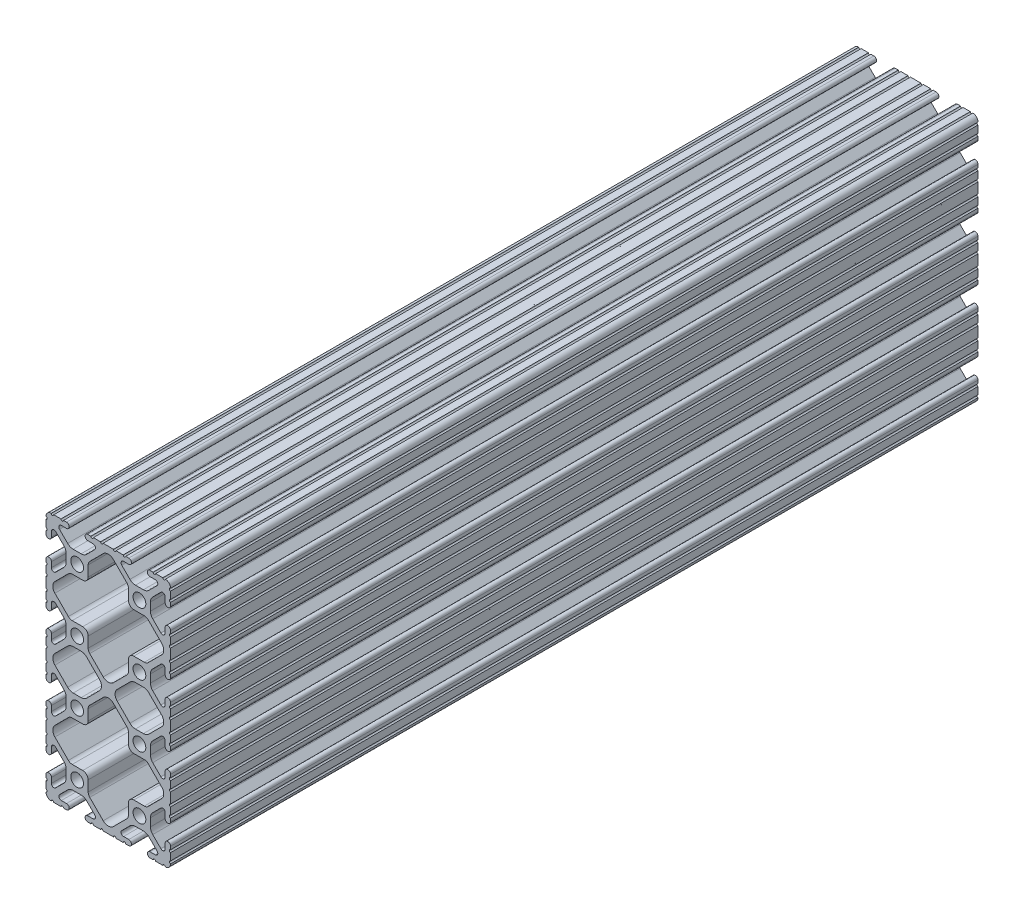
from build123d import *

# Parameters (mm, degrees)
SKETCH1_R      = 2.6035
EXTRUDE1_DEPTH = 329.311


with BuildPart() as part:
    # Sketch1 → Extrude1 (new body)
    with BuildSketch(Plane.XY):
        with BuildLine():
            Line((-12.699984366, 40.2336), (-12.699984366, 35.9664))
            ThreePointArc((-12.699984366, 35.9664), (-12.192, 35.458392183), (-12.7, 34.9504))
            Line((-12.7, 34.9504), (-12.7, 32.004))
            ThreePointArc((-12.7, 32.004), (-12.192, 31.496), (-12.7, 30.988))
            Line((-12.7, 30.988), (-12.7, 29.7434))
            ThreePointArc((-12.7, 29.7434), (-11.5951, 28.6385), (-10.4902, 29.7434))
            Line((-10.4902, 29.7434), (-10.4902, 31.874256981))
            ThreePointArc((-10.4902, 31.874256981), (-9.863010627, 32.812916821), (-8.755786031, 32.592683991))
            Line((-8.755786031, 32.592683991), (-5.425756348, 29.262714761))
            ThreePointArc((-5.425756348, 29.262714761), (-4.737487999, 28.232663563), (-4.4958, 27.017630353))
            Line((-4.4958, 27.017630353), (-4.4958, 23.782369647))
            ThreePointArc((-4.4958, 23.782369647), (-4.737487999, 22.567336437), (-5.425756348, 21.537285239))
            Line((-5.425756348, 21.537285239), (-8.755786031, 18.207316009))
            ThreePointArc((-8.755786031, 18.207316009), (-9.863010627, 17.987083179), (-10.4902, 18.925743019))
            Line((-10.4902, 18.925743019), (-10.4902, 21.0566))
            ThreePointArc((-10.4902, 21.0566), (-11.5951, 22.1615), (-12.7, 21.0566))
            Line((-12.7, 21.0566), (-12.7, 19.812))
            ThreePointArc((-12.7, 19.812), (-12.192, 19.304), (-12.7, 18.796))
            Line((-12.7, 18.796), (-12.7, 15.8496))
            ThreePointArc((-12.7, 15.8496), (-12.192, 15.341607817), (-12.699984366, 14.8336))
            Line((-12.699984366, 14.8336), (-12.699984366, 10.5664))
            ThreePointArc((-12.699984366, 10.5664), (-12.192, 10.0584), (-12.699984366, 9.5504))
            Line((-12.699984366, 9.5504), (-12.699984366, 6.604))
            ThreePointArc((-12.699984366, 6.604), (-12.192, 6.095992183), (-12.7, 5.588))
            Line((-12.7, 5.588), (-12.7, 4.3434))
            ThreePointArc((-12.7, 4.3434), (-11.5951, 3.2385), (-10.4902, 4.3434))
            Line((-10.4902, 4.3434), (-10.4902, 6.474256981))
            ThreePointArc((-10.4902, 6.474256981), (-9.863010627, 7.412916821), (-8.755786031, 7.192683991))
            Line((-8.755786031, 7.192683991), (-5.425756348, 3.862714761))
            ThreePointArc((-5.425756348, 3.862714761), (-4.737487999, 2.832663563), (-4.4958, 1.617630353))
            Line((-4.4958, 1.617630353), (-4.4958, -1.617630353))
            ThreePointArc((-4.4958, -1.617630353), (-4.737487999, -2.832663563), (-5.425756348, -3.862714761))
            Line((-5.425756348, -3.862714761), (-8.755786031, -7.192683991))
            ThreePointArc((-8.755786031, -7.192683991), (-9.863010627, -7.412916821), (-10.4902, -6.474256981))
            Line((-10.4902, -6.474256981), (-10.4902, -4.3434))
            ThreePointArc((-10.4902, -4.3434), (-11.5951, -3.2385), (-12.7, -4.3434))
            Line((-12.7, -4.3434), (-12.7, -5.588))
            ThreePointArc((-12.7, -5.588), (-12.192, -6.096), (-12.7, -6.604))
            Line((-12.7, -6.604), (-12.7, -9.5504))
            ThreePointArc((-12.7, -9.5504), (-12.192000007, -10.058315768), (-12.699831537, -10.566399972))
            ThreePointArc((-12.699831537, -10.566399972), (-12.082506882, -12.082506882), (-10.566399972, -12.699831537))
            ThreePointArc((-10.566399972, -12.699831537), (-10.058315768, -12.192000007), (-9.5504, -12.7))
            Line((-9.5504, -12.7), (-6.604, -12.7))
            ThreePointArc((-6.604, -12.7), (-6.096, -12.192), (-5.588, -12.7))
            Line((-5.588, -12.7), (-4.3434, -12.7))
            ThreePointArc((-4.3434, -12.7), (-3.2385, -11.5951), (-4.3434, -10.4902))
            Line((-4.3434, -10.4902), (-6.474256981, -10.4902))
            ThreePointArc((-6.474256981, -10.4902), (-7.412916821, -9.863010627), (-7.192683991, -8.755786031))
            Line((-7.192683991, -8.755786031), (-3.862714761, -5.425756348))
            ThreePointArc((-3.862714761, -5.425756348), (-2.832663563, -4.737487999), (-1.617630353, -4.4958))
            Line((-1.617630353, -4.4958), (1.617630353, -4.4958))
            ThreePointArc((1.617630353, -4.4958), (2.832663563, -4.737487999), (3.862714761, -5.425756348))
            Line((3.862714761, -5.425756348), (7.192683991, -8.755786031))
            ThreePointArc((7.192683991, -8.755786031), (7.412916821, -9.863010627), (6.474256981, -10.4902))
            Line((6.474256981, -10.4902), (4.3434, -10.4902))
            ThreePointArc((4.3434, -10.4902), (3.2385, -11.5951), (4.3434, -12.7))
            Line((4.3434, -12.7), (5.588, -12.7))
            ThreePointArc((5.588, -12.7), (6.096, -12.192), (6.604, -12.7))
            Line((6.604, -12.7), (9.5504, -12.7))
            ThreePointArc((9.5504, -12.7), (10.0584, -12.192), (10.5664, -12.7))
            Line((10.5664, -12.7), (14.8336, -12.7))
            ThreePointArc((14.8336, -12.7), (15.3416, -12.192), (15.8496, -12.7))
            Line((15.8496, -12.7), (18.796, -12.7))
            ThreePointArc((18.796, -12.7), (19.304, -12.192), (19.812, -12.7))
            Line((19.812, -12.7), (21.0566, -12.7))
            ThreePointArc((21.0566, -12.7), (22.1615, -11.5951), (21.0566, -10.4902))
            Line((21.0566, -10.4902), (18.925743019, -10.4902))
            ThreePointArc((18.925743019, -10.4902), (17.987083179, -9.863010627), (18.207316009, -8.755786031))
            Line((18.207316009, -8.755786031), (21.537285239, -5.425756348))
            ThreePointArc((21.537285239, -5.425756348), (22.567336437, -4.737487999), (23.782369647, -4.4958))
            Line((23.782369647, -4.4958), (27.017630353, -4.4958))
            ThreePointArc((27.017630353, -4.4958), (28.232663563, -4.737487999), (29.262714761, -5.425756348))
            Line((29.262714761, -5.425756348), (32.592683991, -8.755786031))
            ThreePointArc((32.592683991, -8.755786031), (32.812916821, -9.863010627), (31.874256981, -10.4902))
            Line((31.874256981, -10.4902), (29.7434, -10.4902))
            ThreePointArc((29.7434, -10.4902), (28.6385, -11.5951), (29.7434, -12.7))
            Line((29.7434, -12.7), (30.988, -12.7))
            ThreePointArc((30.988, -12.7), (31.496, -12.192), (32.004, -12.7))
            Line((32.004, -12.7), (34.9504, -12.7))
            ThreePointArc((34.9504, -12.7), (35.458315768, -12.192000007), (35.966399972, -12.699831537))
            ThreePointArc((35.966399972, -12.699831537), (37.482506882, -12.082506882), (38.099831537, -10.566399972))
            ThreePointArc((38.099831537, -10.566399972), (37.592000007, -10.058315768), (38.1, -9.5504))
            Line((38.1, -9.5504), (38.1, -6.604))
            ThreePointArc((38.1, -6.604), (37.592, -6.096), (38.1, -5.588))
            Line((38.1, -5.588), (38.1, -4.3434))
            ThreePointArc((38.1, -4.3434), (36.9951, -3.2385), (35.8902, -4.3434))
            Line((35.8902, -4.3434), (35.8902, -6.474256981))
            ThreePointArc((35.8902, -6.474256981), (35.263010627, -7.412916821), (34.155786031, -7.192683991))
            Line((34.155786031, -7.192683991), (30.825756348, -3.862714761))
            ThreePointArc((30.825756348, -3.862714761), (30.137487999, -2.832663563), (29.8958, -1.617630353))
            Line((29.8958, -1.617630353), (29.8958, 1.617630353))
            ThreePointArc((29.8958, 1.617630353), (30.137487999, 2.832663563), (30.825756348, 3.862714761))
            Line((30.825756348, 3.862714761), (34.155786031, 7.192683991))
            ThreePointArc((34.155786031, 7.192683991), (35.263010627, 7.412916821), (35.8902, 6.474256981))
            Line((35.8902, 6.474256981), (35.8902, 4.3434))
            ThreePointArc((35.8902, 4.3434), (36.9951, 3.2385), (38.1, 4.3434))
            Line((38.1, 4.3434), (38.1, 5.588))
            ThreePointArc((38.1, 5.588), (37.592, 6.096), (38.1, 6.604))
            Line((38.1, 6.604), (38.1, 9.5504))
            ThreePointArc((38.1, 9.5504), (37.592, 10.058392183), (38.099984366, 10.5664))
            Line((38.099984366, 10.5664), (38.099984366, 14.8336))
            ThreePointArc((38.099984366, 14.8336), (37.592, 15.3416), (38.099984366, 15.8496))
            Line((38.099984366, 15.8496), (38.099984366, 18.796))
            ThreePointArc((38.099984366, 18.796), (37.592, 19.304007817), (38.1, 19.812))
            Line((38.1, 19.812), (38.1, 21.0566))
            ThreePointArc((38.1, 21.0566), (36.9951, 22.1615), (35.8902, 21.0566))
            Line((35.8902, 21.0566), (35.8902, 18.925743019))
            ThreePointArc((35.8902, 18.925743019), (35.263010627, 17.987083179), (34.155786031, 18.207316009))
            Line((34.155786031, 18.207316009), (30.825756348, 21.537285239))
            ThreePointArc((30.825756348, 21.537285239), (30.137487999, 22.567336437), (29.8958, 23.782369647))
            Line((29.8958, 23.782369647), (29.8958, 27.017630353))
            ThreePointArc((29.8958, 27.017630353), (30.137487999, 28.232663563), (30.825756348, 29.262714761))
            Line((30.825756348, 29.262714761), (34.155786031, 32.592683991))
            ThreePointArc((34.155786031, 32.592683991), (35.263010627, 32.812916821), (35.8902, 31.874256981))
            Line((35.8902, 31.874256981), (35.8902, 29.7434))
            ThreePointArc((35.8902, 29.7434), (36.9951, 28.6385), (38.1, 29.7434))
            Line((38.1, 29.7434), (38.1, 30.988))
            ThreePointArc((38.1, 30.988), (37.592, 31.495992183), (38.099984366, 32.004))
            Line((38.099984366, 32.004), (38.099984366, 34.9504))
            ThreePointArc((38.099984366, 34.9504), (37.592, 35.4584), (38.099984366, 35.9664))
            Line((38.099984366, 35.9664), (38.099984366, 40.2336))
            ThreePointArc((38.099984366, 40.2336), (37.592, 40.7416), (38.099984366, 41.2496))
            Line((38.099984366, 41.2496), (38.099984366, 44.196))
            ThreePointArc((38.099984366, 44.196), (37.592, 44.704007817), (38.1, 45.212))
            Line((38.1, 45.212), (38.1, 46.4566))
            ThreePointArc((38.1, 46.4566), (36.9951, 47.5615), (35.8902, 46.4566))
            Line((35.8902, 46.4566), (35.8902, 44.325743019))
            ThreePointArc((35.8902, 44.325743019), (35.263010627, 43.387083179), (34.155786031, 43.607316009))
            Line((34.155786031, 43.607316009), (30.825756348, 46.937285239))
            ThreePointArc((30.825756348, 46.937285239), (30.137487999, 47.967336437), (29.8958, 49.182369647))
            Line((29.8958, 49.182369647), (29.8958, 52.417630353))
            ThreePointArc((29.8958, 52.417630353), (30.137487999, 53.632663563), (30.825756348, 54.662714761))
            Line((30.825756348, 54.662714761), (34.155786031, 57.992683991))
            ThreePointArc((34.155786031, 57.992683991), (35.263010627, 58.212916821), (35.8902, 57.274256981))
            Line((35.8902, 57.274256981), (35.8902, 55.1434))
            ThreePointArc((35.8902, 55.1434), (36.9951, 54.0385), (38.1, 55.1434))
            Line((38.1, 55.1434), (38.1, 56.388))
            ThreePointArc((38.1, 56.388), (37.592, 56.896), (38.1, 57.404))
            Line((38.1, 57.404), (38.1, 60.3504))
            ThreePointArc((38.1, 60.3504), (37.592, 60.858392183), (38.099984366, 61.3664))
            Line((38.099984366, 61.3664), (38.099984366, 65.6336))
            ThreePointArc((38.099984366, 65.6336), (37.592, 66.141607817), (38.1, 66.6496))
            Line((38.1, 66.6496), (38.1, 69.596))
            ThreePointArc((38.1, 69.596), (37.592, 70.104), (38.1, 70.612))
            Line((38.1, 70.612), (38.1, 71.8566))
            ThreePointArc((38.1, 71.8566), (36.9951, 72.9615), (35.8902, 71.8566))
            Line((35.8902, 71.8566), (35.8902, 69.725743019))
            ThreePointArc((35.8902, 69.725743019), (35.263010627, 68.787083179), (34.155786031, 69.007316009))
            Line((34.155786031, 69.007316009), (30.825756348, 72.337285239))
            ThreePointArc((30.825756348, 72.337285239), (30.137487999, 73.367336437), (29.8958, 74.582369647))
            Line((29.8958, 74.582369647), (29.8958, 77.817630353))
            ThreePointArc((29.8958, 77.817630353), (30.137487999, 79.032663563), (30.825756348, 80.062714761))
            Line((30.825756348, 80.062714761), (34.155786031, 83.392683991))
            ThreePointArc((34.155786031, 83.392683991), (35.263010627, 83.612916821), (35.8902, 82.674256981))
            Line((35.8902, 82.674256981), (35.8902, 80.5434))
            ThreePointArc((35.8902, 80.5434), (36.9951, 79.4385), (38.1, 80.5434))
            Line((38.1, 80.5434), (38.1, 81.788))
            ThreePointArc((38.1, 81.788), (37.592, 82.296), (38.1, 82.804))
            Line((38.1, 82.804), (38.1, 85.7504))
            ThreePointArc((38.1, 85.7504), (37.592000007, 86.258315768), (38.099831537, 86.766399972))
            ThreePointArc((38.099831537, 86.766399972), (37.482506882, 88.282506882), (35.966399972, 88.899831537))
            ThreePointArc((35.966399972, 88.899831537), (35.458315768, 88.392000007), (34.9504, 88.9))
            Line((34.9504, 88.9), (32.004, 88.9))
            ThreePointArc((32.004, 88.9), (31.496, 88.392), (30.988, 88.9))
            Line((30.988, 88.9), (29.7434, 88.9))
            ThreePointArc((29.7434, 88.9), (28.6385, 87.7951), (29.7434, 86.6902))
            Line((29.7434, 86.6902), (31.874256981, 86.6902))
            ThreePointArc((31.874256981, 86.6902), (32.812916821, 86.063010627), (32.592683991, 84.955786031))
            Line((32.592683991, 84.955786031), (29.262714761, 81.625756348))
            ThreePointArc((29.262714761, 81.625756348), (28.232663563, 80.937487999), (27.017630353, 80.6958))
            Line((27.017630353, 80.6958), (23.782369647, 80.6958))
            ThreePointArc((23.782369647, 80.6958), (22.567336437, 80.937487999), (21.537285239, 81.625756348))
            Line((21.537285239, 81.625756348), (18.207316009, 84.955786031))
            ThreePointArc((18.207316009, 84.955786031), (17.987083179, 86.063010627), (18.925743019, 86.6902))
            Line((18.925743019, 86.6902), (21.0566, 86.6902))
            ThreePointArc((21.0566, 86.6902), (22.1615, 87.7951), (21.0566, 88.9))
            Line((21.0566, 88.9), (19.812, 88.9))
            ThreePointArc((19.812, 88.9), (19.304, 88.392), (18.796, 88.9))
            Line((18.796, 88.9), (15.8496, 88.9))
            ThreePointArc((15.8496, 88.9), (15.3416, 88.392), (14.8336, 88.9))
            Line((14.8336, 88.9), (10.5664, 88.9))
            ThreePointArc((10.5664, 88.9), (10.0584, 88.392), (9.5504, 88.9))
            Line((9.5504, 88.9), (6.604, 88.9))
            ThreePointArc((6.604, 88.9), (6.096, 88.392), (5.588, 88.9))
            Line((5.588, 88.9), (4.3434, 88.9))
            ThreePointArc((4.3434, 88.9), (3.2385, 87.7951), (4.3434, 86.6902))
            Line((4.3434, 86.6902), (6.474256981, 86.6902))
            ThreePointArc((6.474256981, 86.6902), (7.412916821, 86.063010627), (7.192683991, 84.955786031))
            Line((7.192683991, 84.955786031), (3.862714761, 81.625756348))
            ThreePointArc((3.862714761, 81.625756348), (2.832663563, 80.937487999), (1.617630353, 80.6958))
            Line((1.617630353, 80.6958), (-1.617630353, 80.6958))
            ThreePointArc((-1.617630353, 80.6958), (-2.832663563, 80.937487999), (-3.862714761, 81.625756348))
            Line((-3.862714761, 81.625756348), (-7.192683991, 84.955786031))
            ThreePointArc((-7.192683991, 84.955786031), (-7.412916821, 86.063010627), (-6.474256981, 86.6902))
            Line((-6.474256981, 86.6902), (-4.3434, 86.6902))
            ThreePointArc((-4.3434, 86.6902), (-3.2385, 87.7951), (-4.3434, 88.9))
            Line((-4.3434, 88.9), (-5.588, 88.9))
            ThreePointArc((-5.588, 88.9), (-6.096, 88.392), (-6.604, 88.9))
            Line((-6.604, 88.9), (-9.5504, 88.9))
            ThreePointArc((-9.5504, 88.9), (-10.058315768, 88.392000007), (-10.566399972, 88.899831537))
            ThreePointArc((-10.566399972, 88.899831537), (-12.082506882, 88.282506882), (-12.699831537, 86.766399972))
            ThreePointArc((-12.699831537, 86.766399972), (-12.192000007, 86.258315768), (-12.7, 85.7504))
            Line((-12.7, 85.7504), (-12.7, 82.804))
            ThreePointArc((-12.7, 82.804), (-12.192, 82.296), (-12.7, 81.788))
            Line((-12.7, 81.788), (-12.7, 80.5434))
            ThreePointArc((-12.7, 80.5434), (-11.5951, 79.4385), (-10.4902, 80.5434))
            Line((-10.4902, 80.5434), (-10.4902, 82.674256981))
            ThreePointArc((-10.4902, 82.674256981), (-9.863010627, 83.612916821), (-8.755786031, 83.392683991))
            Line((-8.755786031, 83.392683991), (-5.425756348, 80.062714761))
            ThreePointArc((-5.425756348, 80.062714761), (-4.737487999, 79.032663563), (-4.4958, 77.817630353))
            Line((-4.4958, 77.817630353), (-4.4958, 74.582369647))
            ThreePointArc((-4.4958, 74.582369647), (-4.737487999, 73.367336437), (-5.425756348, 72.337285239))
            Line((-5.425756348, 72.337285239), (-8.755786031, 69.007316009))
            ThreePointArc((-8.755786031, 69.007316009), (-9.863010627, 68.787083179), (-10.4902, 69.725743019))
            Line((-10.4902, 69.725743019), (-10.4902, 71.8566))
            ThreePointArc((-10.4902, 71.8566), (-11.5951, 72.9615), (-12.7, 71.8566))
            Line((-12.7, 71.8566), (-12.7, 70.612))
            ThreePointArc((-12.7, 70.612), (-12.192, 70.104), (-12.7, 69.596))
            Line((-12.7, 69.596), (-12.7, 66.6496))
            ThreePointArc((-12.7, 66.6496), (-12.192, 66.141607817), (-12.699984366, 65.6336))
            Line((-12.699984366, 65.6336), (-12.699984366, 61.3664))
            ThreePointArc((-12.699984366, 61.3664), (-12.192, 60.858392183), (-12.7, 60.3504))
            Line((-12.7, 60.3504), (-12.7, 57.404))
            ThreePointArc((-12.7, 57.404), (-12.192, 56.896), (-12.7, 56.388))
            Line((-12.7, 56.388), (-12.7, 55.1434))
            ThreePointArc((-12.7, 55.1434), (-11.5951, 54.0385), (-10.4902, 55.1434))
            Line((-10.4902, 55.1434), (-10.4902, 57.274256981))
            ThreePointArc((-10.4902, 57.274256981), (-9.863010627, 58.212916821), (-8.755786031, 57.992683991))
            Line((-8.755786031, 57.992683991), (-5.425756348, 54.662714761))
            ThreePointArc((-5.425756348, 54.662714761), (-4.737487999, 53.632663563), (-4.4958, 52.417630353))
            Line((-4.4958, 52.417630353), (-4.4958, 49.182369647))
            ThreePointArc((-4.4958, 49.182369647), (-4.737487999, 47.967336437), (-5.425756348, 46.937285239))
            Line((-5.425756348, 46.937285239), (-8.755786031, 43.607316009))
            ThreePointArc((-8.755786031, 43.607316009), (-9.863010627, 43.387083179), (-10.4902, 44.325743019))
            Line((-10.4902, 44.325743019), (-10.4902, 46.4566))
            ThreePointArc((-10.4902, 46.4566), (-11.5951, 47.5615), (-12.7, 46.4566))
            Line((-12.7, 46.4566), (-12.7, 45.212))
            ThreePointArc((-12.7, 45.212), (-12.192, 44.704), (-12.7, 44.196))
            Line((-12.7, 44.196), (-12.7, 41.2496))
            ThreePointArc((-12.7, 41.2496), (-12.192, 40.741607817), (-12.699984366, 40.2336))
        make_face()
        with Locations((25.4, 76.2)):
            Circle(SKETCH1_R, mode=Mode.SUBTRACT)
        with Locations((0, 76.2)):
            Circle(SKETCH1_R, mode=Mode.SUBTRACT)
        with Locations((25.4, 50.8)):
            Circle(SKETCH1_R, mode=Mode.SUBTRACT)
        with Locations((0, 50.8)):
            Circle(SKETCH1_R, mode=Mode.SUBTRACT)
        with Locations((25.4, 0)):
            Circle(SKETCH1_R, mode=Mode.SUBTRACT)
        Circle(SKETCH1_R, mode=Mode.SUBTRACT)
        with Locations((25.4, 25.4)):
            Circle(SKETCH1_R, mode=Mode.SUBTRACT)
        with Locations((0, 25.4)):
            Circle(SKETCH1_R, mode=Mode.SUBTRACT)
        with BuildLine():
            Line((2.286, 55.2958), (-2.018378203, 55.2958))
            ThreePointArc((-2.018378203, 55.2958), (-2.864022786, 55.464007171), (-3.580928584, 55.943021252))
            Line((-3.580928584, 55.943021252), (-9.072529371, 61.434522344))
            ThreePointArc((-9.072529371, 61.434522344), (-9.928089211, 63.5), (-9.072529371, 65.565477656))
            Line((-9.072529371, 65.565477656), (-3.580928584, 71.056978748))
            ThreePointArc((-3.580928584, 71.056978748), (-2.864022786, 71.535992829), (-2.018378203, 71.7042))
            Line((-2.018378203, 71.7042), (2.286, 71.7042))
            ThreePointArc((2.286, 71.7042), (3.848564565, 72.351435435), (4.4958, 73.914))
            Line((4.4958, 73.914), (4.4958, 78.218378203))
            ThreePointArc((4.4958, 78.218378203), (4.664007171, 79.064022786), (5.143021252, 79.780928584))
            Line((5.143021252, 79.780928584), (10.634522344, 85.272529371))
            ThreePointArc((10.634522344, 85.272529371), (12.7, 86.128089211), (14.765477656, 85.272529371))
            Line((14.765477656, 85.272529371), (20.256978748, 79.780928584))
            ThreePointArc((20.256978748, 79.780928584), (20.735992829, 79.064022786), (20.9042, 78.218378203))
            Line((20.9042, 78.218378203), (20.9042, 73.914))
            ThreePointArc((20.9042, 73.914), (21.551435435, 72.351435435), (23.114, 71.7042))
            Line((23.114, 71.7042), (27.418378203, 71.7042))
            ThreePointArc((27.418378203, 71.7042), (28.264022786, 71.535992829), (28.980928584, 71.056978748))
            Line((28.980928584, 71.056978748), (34.472529371, 65.565477656))
            ThreePointArc((34.472529371, 65.565477656), (35.328089211, 63.5), (34.472529371, 61.434522344))
            Line((34.472529371, 61.434522344), (28.980928584, 55.943021252))
            ThreePointArc((28.980928584, 55.943021252), (28.264022786, 55.464007171), (27.418378203, 55.2958))
            Line((27.418378203, 55.2958), (23.114, 55.2958))
            ThreePointArc((23.114, 55.2958), (21.551435435, 54.648564565), (20.9042, 53.086))
            Line((20.9042, 53.086), (20.9042, 48.781621797))
            ThreePointArc((20.9042, 48.781621797), (20.735992829, 47.935977214), (20.256978748, 47.219071416))
            Line((20.256978748, 47.219071416), (14.765477656, 41.727470629))
            ThreePointArc((14.765477656, 41.727470629), (12.7, 40.871910789), (10.634522344, 41.727470629))
            Line((10.634522344, 41.727470629), (5.143021252, 47.219071416))
            ThreePointArc((5.143021252, 47.219071416), (4.664007171, 47.935977214), (4.4958, 48.781621797))
            Line((4.4958, 48.781621797), (4.4958, 53.086))
            ThreePointArc((4.4958, 53.086), (3.848564565, 54.648564565), (2.286, 55.2958))
        make_face(mode=Mode.SUBTRACT)
        with BuildLine():
            Line((4.4958, 23.114), (4.4958, 27.418378203))
            ThreePointArc((4.4958, 27.418378203), (4.664007171, 28.264022786), (5.143021252, 28.980928584))
            Line((5.143021252, 28.980928584), (10.634522344, 34.472529371))
            ThreePointArc((10.634522344, 34.472529371), (12.7, 35.328089211), (14.765477656, 34.472529371))
            Line((14.765477656, 34.472529371), (20.256978748, 28.980928584))
            ThreePointArc((20.256978748, 28.980928584), (20.735992829, 28.264022786), (20.9042, 27.418378203))
            Line((20.9042, 27.418378203), (20.9042, 23.114))
            ThreePointArc((20.9042, 23.114), (21.551435435, 21.551435435), (23.114, 20.9042))
            Line((23.114, 20.9042), (27.418378203, 20.9042))
            ThreePointArc((27.418378203, 20.9042), (28.264022786, 20.735992829), (28.980928584, 20.256978748))
            Line((28.980928584, 20.256978748), (34.472529371, 14.765477656))
            ThreePointArc((34.472529371, 14.765477656), (35.328089211, 12.7), (34.472529371, 10.634522344))
            Line((34.472529371, 10.634522344), (28.980928584, 5.143021252))
            ThreePointArc((28.980928584, 5.143021252), (28.264022786, 4.664007171), (27.418378203, 4.4958))
            Line((27.418378203, 4.4958), (23.114, 4.4958))
            ThreePointArc((23.114, 4.4958), (21.551435435, 3.848564565), (20.9042, 2.286))
            Line((20.9042, 2.286), (20.9042, -2.018378203))
            ThreePointArc((20.9042, -2.018378203), (20.735992829, -2.864022786), (20.256978748, -3.580928584))
            Line((20.256978748, -3.580928584), (14.765477656, -9.072529371))
            ThreePointArc((14.765477656, -9.072529371), (12.7, -9.928089211), (10.634522344, -9.072529371))
            Line((10.634522344, -9.072529371), (5.143021252, -3.580928584))
            ThreePointArc((5.143021252, -3.580928584), (4.664007171, -2.864022786), (4.4958, -2.018378203))
            Line((4.4958, -2.018378203), (4.4958, 2.286))
            ThreePointArc((4.4958, 2.286), (3.848564565, 3.848564565), (2.286, 4.4958))
            Line((2.286, 4.4958), (-2.018378203, 4.4958))
            ThreePointArc((-2.018378203, 4.4958), (-2.864022786, 4.664007171), (-3.580928584, 5.143021252))
            Line((-3.580928584, 5.143021252), (-9.072529371, 10.634522344))
            ThreePointArc((-9.072529371, 10.634522344), (-9.928089211, 12.7), (-9.072529371, 14.765477656))
            Line((-9.072529371, 14.765477656), (-3.580928584, 20.256978748))
            ThreePointArc((-3.580928584, 20.256978748), (-2.864022786, 20.735992829), (-2.018378203, 20.9042))
            Line((-2.018378203, 20.9042), (2.286, 20.9042))
            ThreePointArc((2.286, 20.9042), (3.848564565, 21.551435435), (4.4958, 23.114))
        make_face(mode=Mode.SUBTRACT)
        with BuildLine():
            Line((27.018584404, 29.8958), (23.782369647, 29.8958))
            ThreePointArc((23.782369647, 29.8958), (22.567336437, 30.137487999), (21.537285239, 30.825756348))
            Line((21.537285239, 30.825756348), (16.328576307, 36.03455984))
            ThreePointArc((16.328576307, 36.03455984), (15.473053963, 38.1), (16.328576307, 40.16544016))
            Line((16.328576307, 40.16544016), (21.537285239, 45.374243652))
            ThreePointArc((21.537285239, 45.374243652), (22.567336437, 46.062512001), (23.782369647, 46.3042))
            Line((23.782369647, 46.3042), (27.018584404, 46.3042))
            ThreePointArc((27.018584404, 46.3042), (28.233590989, 46.06252303), (29.263628056, 45.374284409))
            Line((29.263628056, 45.374284409), (34.472529371, 40.165477656))
            ThreePointArc((34.472529371, 40.165477656), (35.328089211, 38.1), (34.472529371, 36.034522344))
            Line((34.472529371, 36.034522344), (29.263628056, 30.825715591))
            ThreePointArc((29.263628056, 30.825715591), (28.233590989, 30.13747697), (27.018584404, 29.8958))
        make_face(mode=Mode.SUBTRACT)
        with BuildLine():
            Line((1.617630353, 29.8958), (-1.618584404, 29.8958))
            ThreePointArc((-1.618584404, 29.8958), (-2.833590989, 30.13747697), (-3.863628056, 30.825715591))
            Line((-3.863628056, 30.825715591), (-9.072529371, 36.034522344))
            ThreePointArc((-9.072529371, 36.034522344), (-9.928089211, 38.1), (-9.072529371, 40.165477656))
            Line((-9.072529371, 40.165477656), (-3.863628056, 45.374284409))
            ThreePointArc((-3.863628056, 45.374284409), (-2.833590989, 46.06252303), (-1.618584404, 46.3042))
            Line((-1.618584404, 46.3042), (1.617630353, 46.3042))
            ThreePointArc((1.617630353, 46.3042), (2.832663563, 46.062512001), (3.862714761, 45.374243652))
            Line((3.862714761, 45.374243652), (9.071423693, 40.16544016))
            ThreePointArc((9.071423693, 40.16544016), (9.926946037, 38.1), (9.071423693, 36.03455984))
            Line((9.071423693, 36.03455984), (3.862714761, 30.825756348))
            ThreePointArc((3.862714761, 30.825756348), (2.832663563, 30.137487999), (1.617630353, 29.8958))
        make_face(mode=Mode.SUBTRACT)
    extrude(amount=-EXTRUDE1_DEPTH)


solid = part.part
